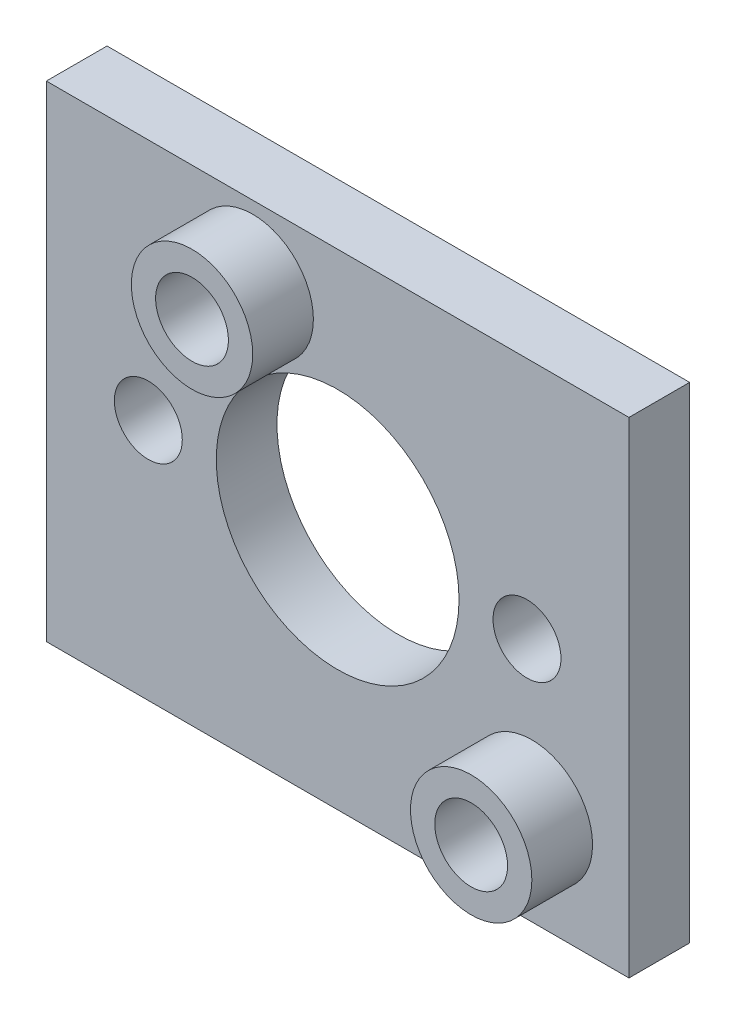
from build123d import *

# Parameters (mm, degrees)
SKETCH1_W           = 30.48
SKETCH1_H           = 25.4
SKETCH1_R           = 6.35
SKETCH1_R_2         = 1.778
BOSS_EXTRUDE1_DEPTH = 3.175
SKETCH2_R           = 3.175
SKETCH2_R_2         = 1.905
BOSS_EXTRUDE2_DEPTH = 3.175


with BuildPart() as part:
    # Sketch1 → Boss-Extrude1 (new body)
    with BuildSketch(Plane.XY):
        Rectangle(SKETCH1_W, SKETCH1_H)
        Circle(SKETCH1_R, mode=Mode.SUBTRACT)
        with Locations((-9.906, 0)):
            Circle(SKETCH1_R_2, mode=Mode.SUBTRACT)
        with Locations((9.906, 0)):
            Circle(SKETCH1_R_2, mode=Mode.SUBTRACT)
    extrude(amount=BOSS_EXTRUDE1_DEPTH)

    # Sketch2 → Boss-Extrude2 (add)
    with BuildSketch(Plane.XY.offset(3.175)):
        with Locations((-4.445, 8.89)):
            Circle(SKETCH2_R)
        with Locations((-4.445, 8.89)):
            Circle(SKETCH2_R_2, mode=Mode.SUBTRACT)
        with Locations((10.16, -7.62)):
            Circle(SKETCH2_R)
        with Locations((10.16, -7.62)):
            Circle(SKETCH2_R_2, mode=Mode.SUBTRACT)
    extrude(amount=BOSS_EXTRUDE2_DEPTH)


solid = part.part
